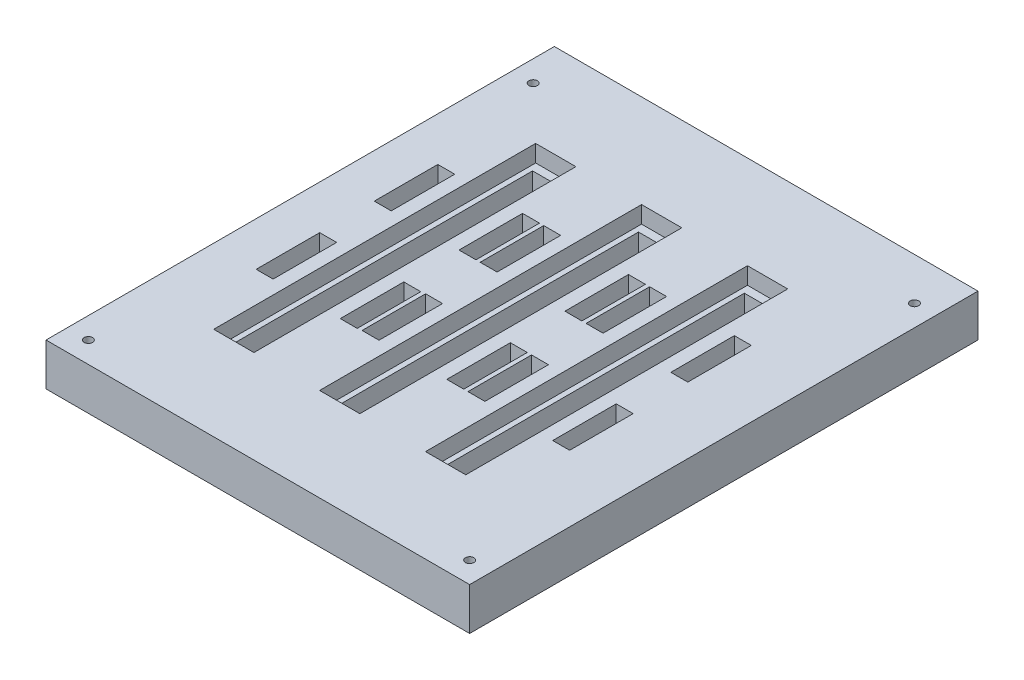
from build123d import *

# Parameters (mm, degrees)
SKETCH2_W           = 100
SKETCH2_H           = 120
SKETCH2_W_2         = 7
SKETCH2_H_2         = 72
BOSS_EXTRUDE1_DEPTH = 10
SKETCH3_W           = 9.5
SKETCH3_H           = 76
SKETCH3_W_2         = 4
SKETCH3_H_2         = 15
CUT_EXTRUDE1_DEPTH  = 4
SKETCH7_R           = 2
CUT_EXTRUDE4_DEPTH  = 5
SKETCH8_R           = 1
CUT_EXTRUDE5_DEPTH  = 5


with BuildPart() as part:
    # Sketch2 → Boss-Extrude1 (new body)
    with BuildSketch(Plane(origin=(0, 0, 0), x_dir=(1, 0, 0), z_dir=(0, 1, 0))):
        Rectangle(SKETCH2_W, SKETCH2_H)
        with Locations((22.353747517, 0)):
            Rectangle(SKETCH2_W_2, SKETCH2_H_2, mode=Mode.SUBTRACT)
        with Locations((-2.646252483, 0)):
            Rectangle(SKETCH2_W_2, SKETCH2_H_2, mode=Mode.SUBTRACT)
        with Locations((-27.646252483, 0)):
            Rectangle(SKETCH2_W_2, SKETCH2_H_2, mode=Mode.SUBTRACT)
    extrude(amount=BOSS_EXTRUDE1_DEPTH)

    # Sketch3 → Cut-Extrude1 (cut)
    with BuildSketch(Plane(origin=(0, 10, 0), x_dir=(1, 0, 0), z_dir=(0, 1, 0))):
        with Locations((-2.646252483, -0.02091915)):
            Rectangle(SKETCH3_W, SKETCH3_H)
        with Locations((-17.646252483, -13.394152505)):
            Rectangle(SKETCH3_W_2, SKETCH3_H_2)
        with Locations((-17.646252483, 14.635235437)):
            Rectangle(SKETCH3_W_2, SKETCH3_H_2)
        with Locations((-37.646252483, 14.635235437)):
            Rectangle(SKETCH3_W_2, SKETCH3_H_2)
        with Locations((-37.646252483, -13.246569784)):
            Rectangle(SKETCH3_W_2, SKETCH3_H_2)
        with Locations((-12.646252483, -13.246569784)):
            Rectangle(SKETCH3_W_2, SKETCH3_H_2)
        with Locations((-12.646252483, 14.635235437)):
            Rectangle(SKETCH3_W_2, SKETCH3_H_2)
        with Locations((7.353747517, 14.635235437)):
            Rectangle(SKETCH3_W_2, SKETCH3_H_2)
        with Locations((12.353747517, 14.635235437)):
            Rectangle(SKETCH3_W_2, SKETCH3_H_2)
        with Locations((12.353747517, -13.246569784)):
            Rectangle(SKETCH3_W_2, SKETCH3_H_2)
        with Locations((7.353747517, -13.246569784)):
            Rectangle(SKETCH3_W_2, SKETCH3_H_2)
        with Locations((32.353747517, -13.246569784)):
            Rectangle(SKETCH3_W_2, SKETCH3_H_2)
        with Locations((32.353747517, 14.635235437)):
            Rectangle(SKETCH3_W_2, SKETCH3_H_2)
        with Locations((-27.646252483, -0.02091915)):
            Rectangle(SKETCH3_W, SKETCH3_H)
        with Locations((22.353747517, -0.02091915)):
            Rectangle(SKETCH3_W, SKETCH3_H)
    extrude(amount=-CUT_EXTRUDE1_DEPTH, mode=Mode.SUBTRACT)

    # Sketch7 → Cut-Extrude4 (cut)
    with BuildSketch(Plane.XZ):
        with Locations((45, -50)):
            Circle(SKETCH7_R)
        with Locations((-45, -50)):
            Circle(SKETCH7_R)
        with Locations((-45, 55)):
            Circle(SKETCH7_R)
        with Locations((45, 55)):
            Circle(SKETCH7_R)
    extrude(amount=-CUT_EXTRUDE4_DEPTH, mode=Mode.SUBTRACT)

    # Sketch8 → Cut-Extrude5 (cut)
    with BuildSketch(Plane(origin=(0, 5, 0), x_dir=(-1, 0, 0), z_dir=(0, -1, 0))):
        with Locations((-45, 50)):
            Circle(SKETCH8_R)
        with Locations((45, 50)):
            Circle(SKETCH8_R)
        with Locations((45, -55)):
            Circle(SKETCH8_R)
        with Locations((-45, -55)):
            Circle(SKETCH8_R)
    extrude(amount=-CUT_EXTRUDE5_DEPTH, mode=Mode.SUBTRACT)


solid = part.part
